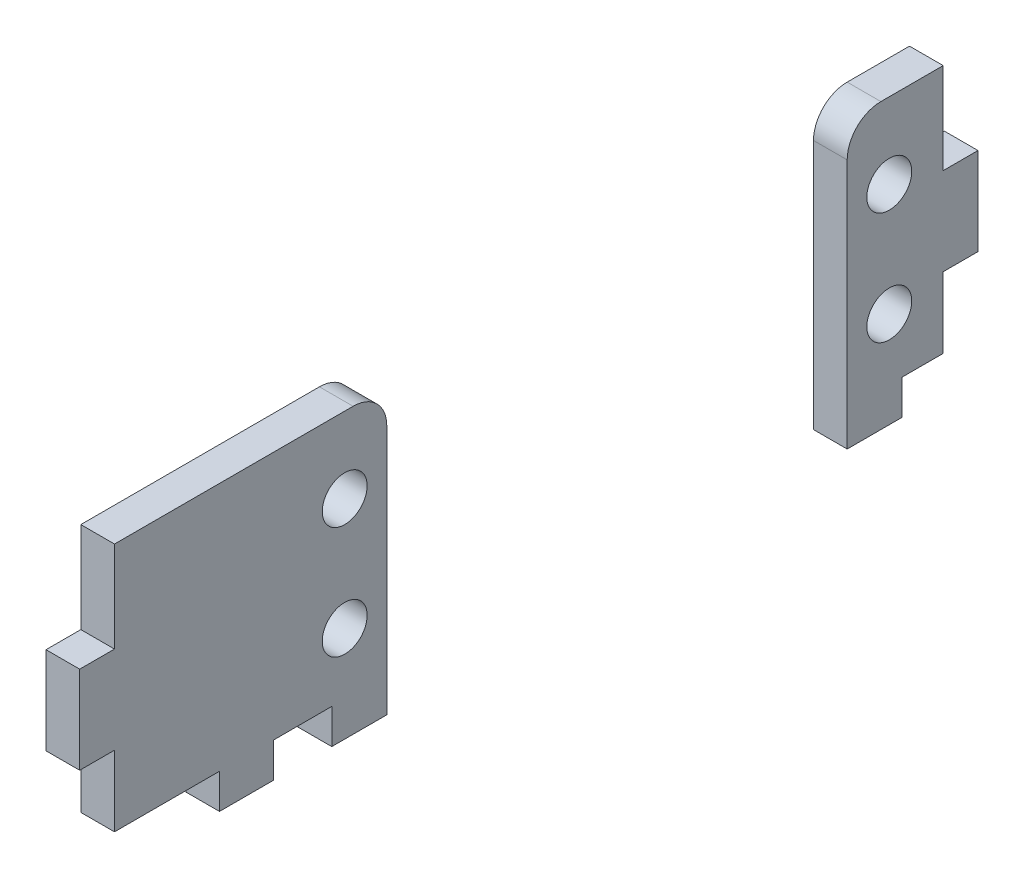
from build123d import *

# Parameters (mm, degrees)
SKETCH1_W             = 27.35
SKETCH1_H             = 25.3
SKETCH1_R             = 2
BOSS_EXTRUDE1_DEPTH   = 3
SKETCH1_W_2           = 11.65
BOSS_EXTRUDE1_2_DEPTH = 3
SKETCH3_W             = 5.2
SKETCH3_H             = 3.2
SKETCH3_W_2           = 3.2
SKETCH3_H_2           = 8.2
CUT_EXTRUDE1_DEPTH    = 4
FILLET1_R             = 3
FILLET2_R             = 3


with BuildPart() as part:
    # Sketch1 → Boss-Extrude1 (new body)
    with BuildSketch(Plane(origin=(0, 0, 0), x_dir=(0, 0, -1), z_dir=(1, 0, 0))):
        with Locations((13.675, -12.65)):
            Rectangle(SKETCH1_W, SKETCH1_H)
        with Locations((23.6, -6.75)):
            Circle(SKETCH1_R, mode=Mode.SUBTRACT)
        with Locations((23.6, -16.75)):
            Circle(SKETCH1_R, mode=Mode.SUBTRACT)
    extrude(amount=-BOSS_EXTRUDE1_DEPTH)


with BuildPart() as body_2:
    # Sketch1 → Boss-Extrude1 2 (new body)
    with BuildSketch(Plane(origin=(0, 0, 0), x_dir=(0, 0, -1), z_dir=(1, 0, 0))):
        with Locations((74.175, -12.65)):
            Rectangle(SKETCH1_W_2, SKETCH1_H)
        with Locations((72.1, -6.75)):
            Circle(SKETCH1_R, mode=Mode.SUBTRACT)
        with Locations((72.1, -16.75)):
            Circle(SKETCH1_R, mode=Mode.SUBTRACT)
    extrude(amount=-BOSS_EXTRUDE1_2_DEPTH)


with BuildPart() as cut_extrude1_tool:
    # Sketch3 → Cut-Extrude1 (new body, through all)
    with BuildSketch(Plane(origin=(0, 0, 0), x_dir=(0, 0, -1), z_dir=(1, 0, 0))):
        with Locations((19.85, -23.8)):
            Rectangle(SKETCH3_W, SKETCH3_H)
        with Locations((78.5, -4)):
            Rectangle(SKETCH3_W_2, SKETCH3_H_2)
        with Locations((1.5, -4)):
            Rectangle(SKETCH3_W_2, SKETCH3_H_2)
        Polygon((76.9, -15.9), (76.9, -22.2), (73.25, -22.2), (73.25, -25.4), (80.1, -25.4), (80.1, -15.9), align=None)
        Polygon((12.45, -22.2), (3.1, -22.2), (3.1, -15.9), (-0.1, -15.9), (-0.1, -25.4), (12.45, -25.4), align=None)
    extrude(amount=-CUT_EXTRUDE1_DEPTH)


with BuildPart() as part_1:
    add(part.part)

    # Cut-Extrude1: cut by cut_extrude1_tool
    add(cut_extrude1_tool.part, mode=Mode.SUBTRACT)

    # Fillet1
    fillet1_edges = [part_1.edges().sort_by_distance(p)[0] for p in [
        (-1.5, 0, -27.35),
    ]]
    fillet(fillet1_edges, radius=FILLET1_R)


with BuildPart() as body_2_1:
    add(body_2.part)

    # Cut-Extrude1: cut by cut_extrude1_tool
    add(cut_extrude1_tool.part, mode=Mode.SUBTRACT)

    # Fillet2
    fillet2_edges = [body_2_1.edges().sort_by_distance(p)[0] for p in [
        (-1.5, 0, -68.35),
    ]]
    fillet(fillet2_edges, radius=FILLET2_R)


solid = Compound([part_1.part, body_2_1.part])
